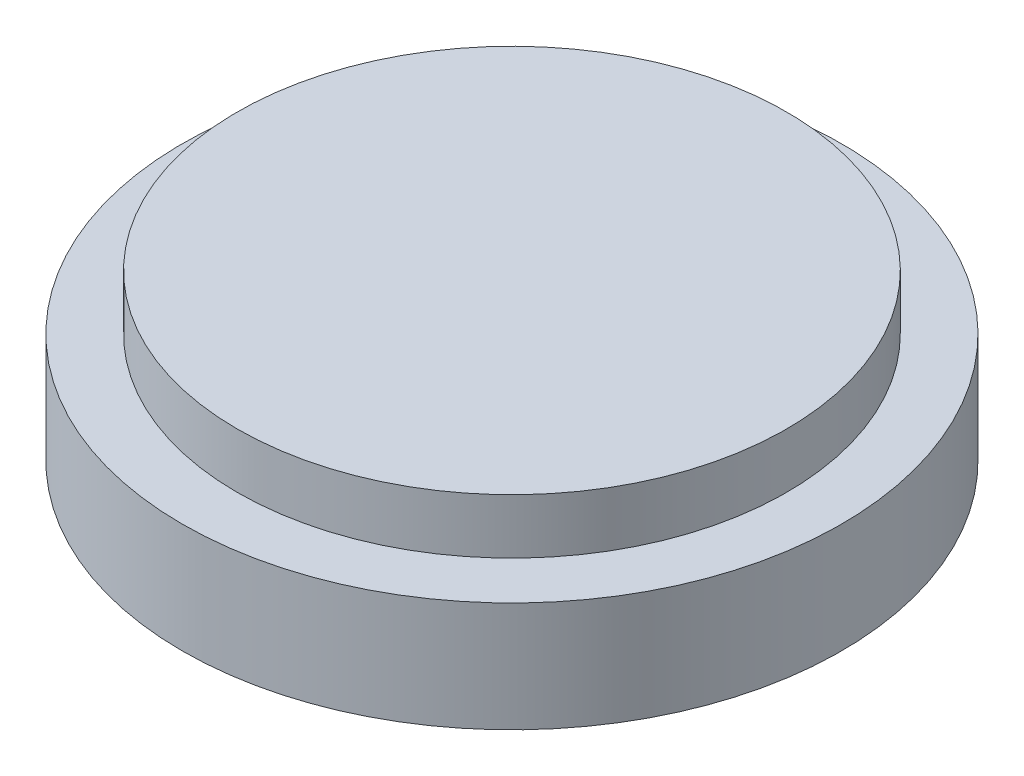
from build123d import *

# Parameters (mm, degrees)
SKETCH1_R           = 600
BOSS_EXTRUDE1_DEPTH = 200
SKETCH3_R           = 500
BOSS_EXTRUDE2_DEPTH = 100


with BuildPart() as part:
    # Sketch1 → Boss-Extrude1 (new body)
    with BuildSketch(Plane(origin=(0, 0, 0), x_dir=(1, 0, 0), z_dir=(0, 1, 0))):
        Circle(SKETCH1_R)
    extrude(amount=BOSS_EXTRUDE1_DEPTH)

    # Sketch3 → Boss-Extrude2 (add)
    with BuildSketch(Plane(origin=(0, 200, 0), x_dir=(1, 0, 0), z_dir=(0, 1, 0))):
        Circle(SKETCH3_R)
    extrude(amount=BOSS_EXTRUDE2_DEPTH)


solid = part.part
